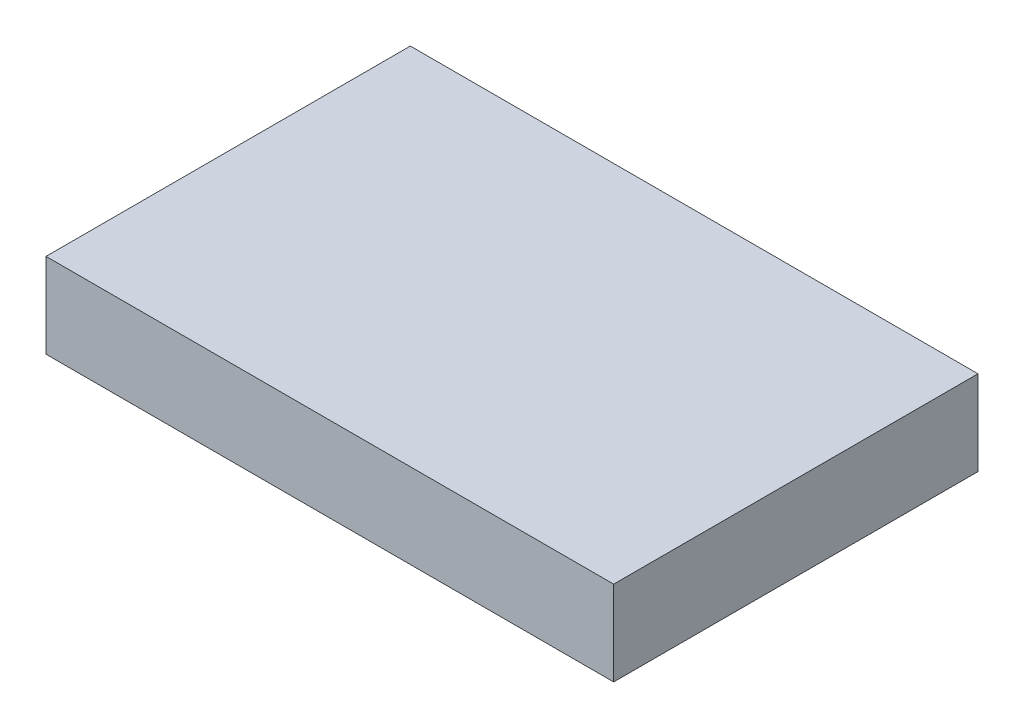
from build123d import *

# Parameters (mm, degrees)
SKETCH1_W           = 17.018
SKETCH1_H           = 10.922
BOSS_EXTRUDE1_DEPTH = 2.54


with BuildPart() as part:
    # Sketch1 → Boss-Extrude1 (new body)
    with BuildSketch(Plane(origin=(0, 0, 0), x_dir=(1, 0, 0), z_dir=(0, 1, 0))):
        with Locations((8.509, 5.461)):
            Rectangle(SKETCH1_W, SKETCH1_H)
    extrude(amount=BOSS_EXTRUDE1_DEPTH)


solid = part.part
